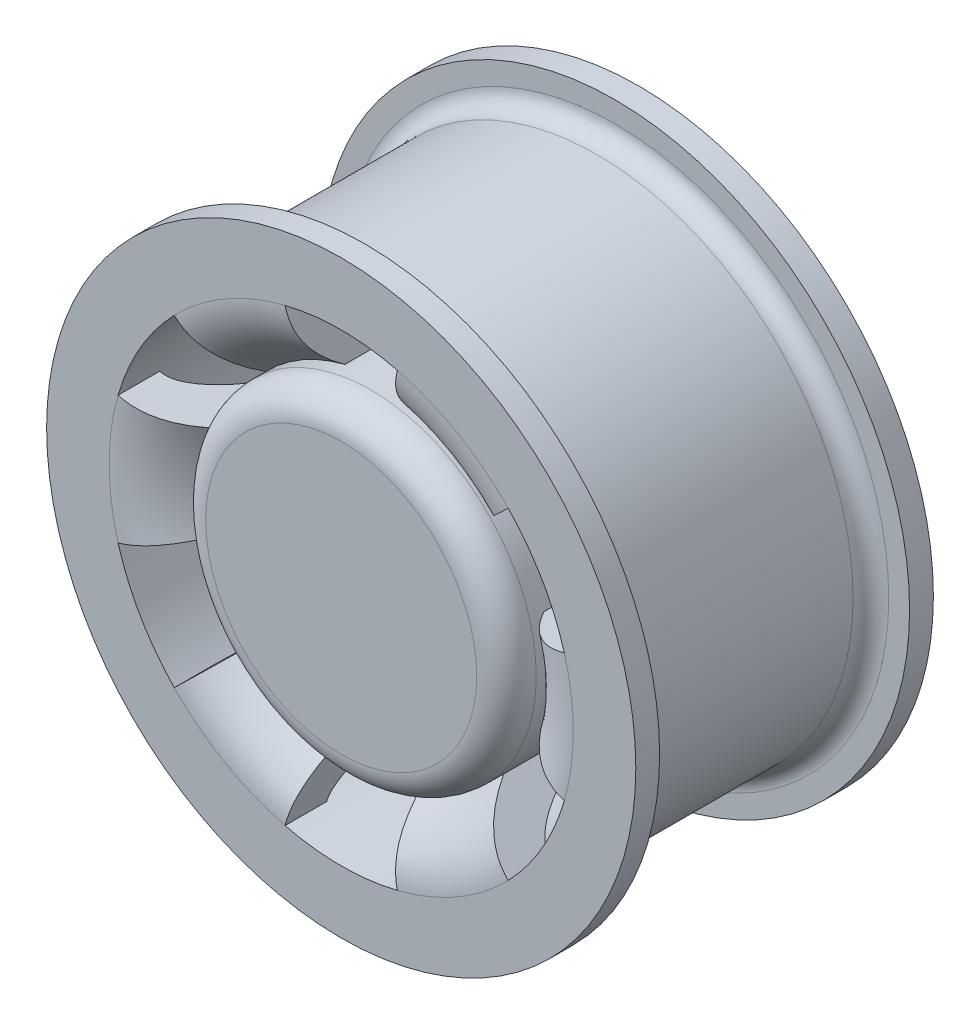
from build123d import *

# Parameters (mm, degrees)
SKETCH_2_R               = 27.769554
SKETCH_2_R_2             = 20.5
EXTRUDE_1_DEPTH          = 25
SKETCH_3_R               = 27.769554
EXTRUDE_2_DEPTH          = 5
CUT_EXTRUDE_1_DEPTH      = 87.026159
PATTERN_CIRCULAR_1_COUNT = 6
FILLET_1_R               = 5
PATTERN_CIRCULAR_3_COUNT = 6
CHAMFER_2_SIZE           = 0.6


with BuildPart() as part:
    # Эскиз1 → Повернуть1 (revolve)
    with BuildSketch(Plane(origin=(0, 0, 0), x_dir=(1, 0, 0), z_dir=(0, 1, 0))):
        with BuildLine():
            Line((39, 25), (39, -18))
            add(Edge.make_bspline(
                [(39, -18), (38.774431, -18), (38.315148, -17.953249), (37.695195, -17.760133), (36.953263, -17.377708), (35.803007, -16.524191), (34.148342, -14.728345), (32.195197, -11.61574), (30.475141, -7.974515), (29.298856, -4.853377), (28.52094, -2.505358), (28.085952, -1.087047), (27.852205, -0.287089), (27.769554, 0)],
                knots=[0, 0, 0, 0, 0.0625, 0.125, 0.1875, 0.25, 0.375, 0.5, 0.625, 0.75, 0.8125, 0.875, 0.911973, 0.911973, 0.911973, 0.911973], degree=3))
            Line((27.769554, 0), (20.5, 0))
            add(Edge.make_bspline(
                [(39, -25), (27.486164, -25), (22.238604, -6.323627), (20.5, 0)],
                knots=[0, 0, 0, 0, 1, 1, 1, 1], degree=3))
            Line((39, -25), (47, -25))
            Line((47, -25), (49.5, -25))
            Line((49.5, -25), (49.5, -21))
            Line((49.5, -21), (46, -21))
            ThreePointArc((46, -21), (43.87868, -20.12132), (43, -18))
            Line((43, -18), (43, 18))
            ThreePointArc((43, 18), (43.87868, 20.12132), (46, 21))
            Line((46, 21), (49.5, 21))
            Line((49.5, 21), (49.5, 25))
            Line((49.5, 25), (47, 25))
            Line((47, 25), (39, 25))
        make_face()
    revolve(axis=Axis((0, 0, 0), (0, 0, -1)))

    # Эскиз2 → Бобышка-Вытянуть1 (add, through all)
    with BuildSketch(Plane(origin=(0, 0, 0), x_dir=(-1, 0, 0), z_dir=(0, 0, -1))):
        Circle(SKETCH_2_R)
        Circle(SKETCH_2_R_2, mode=Mode.SUBTRACT)
    extrude(amount=-EXTRUDE_1_DEPTH)

    # Эскиз3 → Бобышка-Вытянуть2 (add)
    with BuildSketch(Plane.XY.offset(25)):
        with Locations(Location((0, 0, 0), (0, 0, 180))):
            Circle(SKETCH_3_R)
    extrude(amount=-EXTRUDE_2_DEPTH)

    # Эскиз4 → Вырез-Вытянуть1 (cut, through all)
    with BuildSketch(Plane.XY.offset(25)):
        with BuildLine():
            Line((-6.718063, 26.94468), (-9.434954, 37.841533))
            ThreePointArc((-9.434954, 37.841533), (0, 39), (9.434954, 37.841533))
            Line((9.434954, 37.841533), (6.718063, 26.94468))
            ThreePointArc((6.718063, 26.94468), (0, 27.769554), (-6.718063, 26.94468))
        make_face()
    cut_extrude_1 = extrude(amount=-CUT_EXTRUDE_1_DEPTH, mode=Mode.SUBTRACT)

    # Круговой массив1: Вырез-Вытянуть1 ×6 about axis
    pattern_circular_1_axis = Axis((0, 0, 0), (0, 0, 1))
    for i in range(1, PATTERN_CIRCULAR_1_COUNT):
        add(cut_extrude_1.rotate(pattern_circular_1_axis, i * 360 / PATTERN_CIRCULAR_1_COUNT), mode=Mode.SUBTRACT)

    # Скругление1
    fillet_1_edges = [part.edges().sort_by_distance(p)[0] for p in [
        (-10.402658, 25.747482, 25),
    ]]
    fillet(fillet_1_edges, radius=FILLET_1_R)

    # Эскиз13 → Сверление под метчик M51 (revolve, cut)
    with BuildSketch(Plane.YZ.offset(-23.75)):
        Polygon((0, 0), (0, 23.261807), (2.1, 22), (2.1, 0), align=None)
    hole_wizard_m51 = revolve(axis=Axis((-23.75, 0, -6.35), (0, 0, 1)), mode=Mode.SUBTRACT)

    # Круговой массив3: Сверление под метчик M51 ×6 about axis
    pattern_circular_3_axis = Axis((0, 0, 0), (0, 0, 1))
    for i in range(1, PATTERN_CIRCULAR_3_COUNT):
        add(hole_wizard_m51.rotate(pattern_circular_3_axis, i * 360 / PATTERN_CIRCULAR_3_COUNT), mode=Mode.SUBTRACT)

    # Фаска2
    chamfer_2_edges = [part.edges().sort_by_distance(p)[0] for p in [
        (-23.75, -2.1, 0),
        (-10.056347, -21.618103, 0),
        (13.693653, -19.518103, 0),
        (23.75, 2.1, 0),
        (10.056347, 21.618103, 0),
        (-13.693653, 19.518103, 0),
    ]]
    chamfer(chamfer_2_edges, length=CHAMFER_2_SIZE)


solid = part.part
